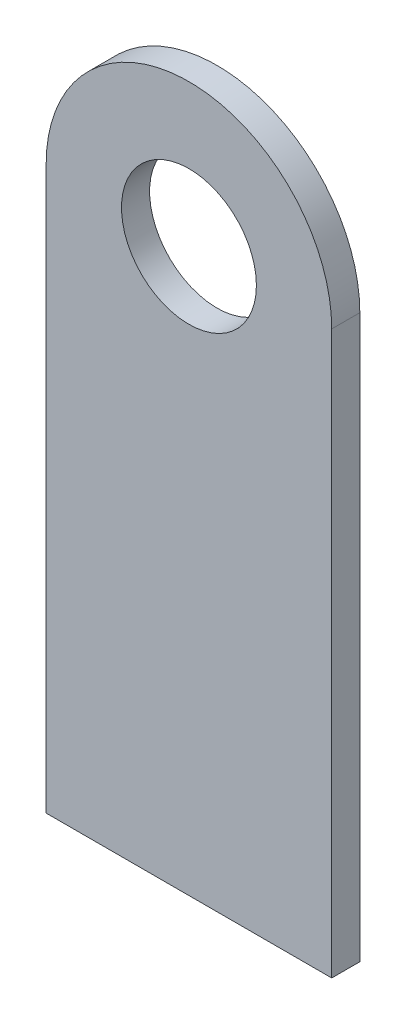
from build123d import *

# Parameters (mm, degrees)
SKETCH1_R           = 6
BOSS_EXTRUDE1_DEPTH = 2.5


with BuildPart() as part:
    # Sketch1 → Boss-Extrude1 (new body)
    with BuildSketch(Plane.XY):
        with BuildLine():
            Line((-12.7, 0), (-12.7, -50))
            Line((-12.7, -50), (12.7, -50))
            Line((12.7, -50), (12.7, 0))
            ThreePointArc((12.7, 0), (0, 12.7), (-12.7, 0))
        make_face()
        Circle(SKETCH1_R, mode=Mode.SUBTRACT)
    extrude(amount=BOSS_EXTRUDE1_DEPTH)


solid = part.part
